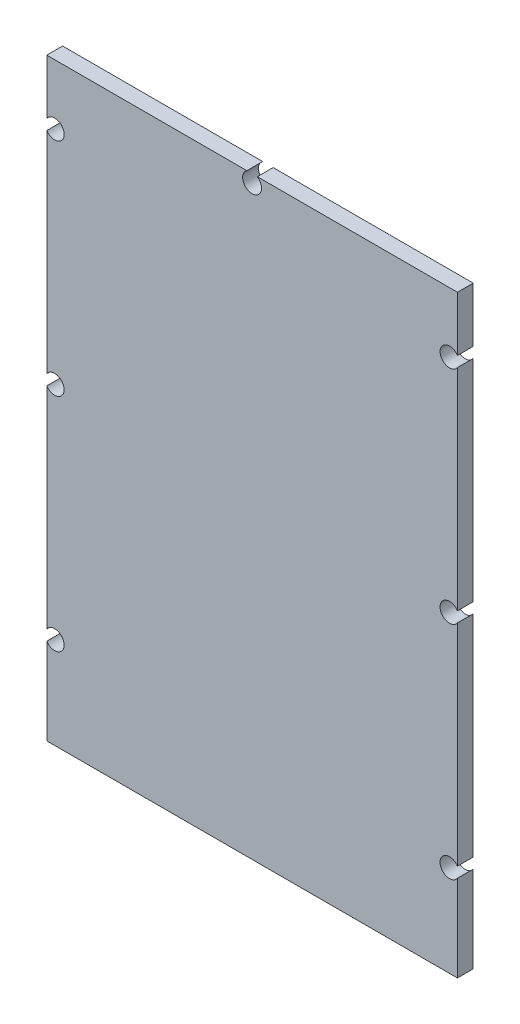
from build123d import *

# Parameters (mm, degrees)
SKETCH1_W               = 65
SKETCH1_H               = 94
BOSS_EXTRUDE1_DEPTH     = 2.5
CUT_EXTRUDE1_START      = -1
SKETCH2_R               = 1.5
CUT_EXTRUDE1_DEPTH      = 4.5
LPATTERN1_COUNT         = 3
LPATTERN1_PITCH         = 35
SKETCH3_R               = 1.5
CUT_EXTRUDE2_DEPTH      = 3.5
CUT_EXTRUDE2_DEPTH_BACK = 1


with BuildPart() as part:
    # Sketch1 → Boss-Extrude1 (new body)
    with BuildSketch(Plane.XY):
        Rectangle(SKETCH1_W, SKETCH1_H)
    extrude(amount=BOSS_EXTRUDE1_DEPTH)

    # Sketch2 → Cut-Extrude1 (cut)
    with BuildSketch(Plane.XY.offset(CUT_EXTRUDE1_START)):
        with Locations((-31.25, 37.5)):
            Circle(SKETCH2_R)
        with Locations((31.25, 37.5)):
            Circle(SKETCH2_R)
    cut_extrude1 = extrude(amount=CUT_EXTRUDE1_DEPTH, mode=Mode.SUBTRACT)

    # LPattern1: Cut-Extrude1 ×3
    with Locations(*[(0, -i * LPATTERN1_PITCH, 0) for i in range(1, LPATTERN1_COUNT)]):
        add(cut_extrude1, mode=Mode.SUBTRACT)

    # Sketch3 → Cut-Extrude2 (cut, two sides)
    with BuildSketch(Plane.XY) as cut_extrude2_sk:
        with Locations((0, 45.75)):
            Circle(SKETCH3_R)
    extrude(amount=CUT_EXTRUDE2_DEPTH, mode=Mode.SUBTRACT)
    extrude(cut_extrude2_sk.sketch, amount=-CUT_EXTRUDE2_DEPTH_BACK, mode=Mode.SUBTRACT)


solid = part.part
